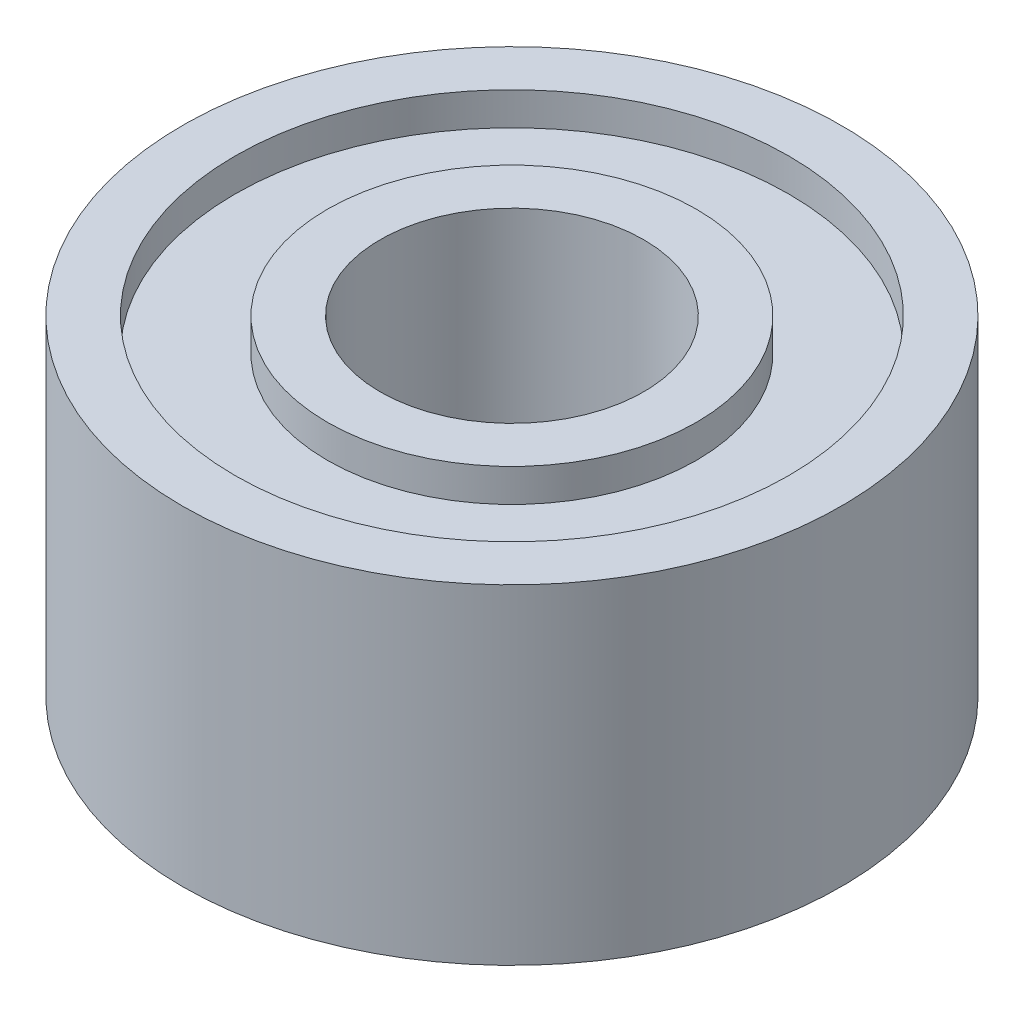
from build123d import *

# Parameters (mm, degrees)
SKETCH1_R           = 2.5
SKETCH1_R_2         = 1
BOSS_EXTRUDE1_DEPTH = 1.25
SKETCH2_R           = 2.1
SKETCH2_R_2         = 1.4
CUT_EXTRUDE1_DEPTH  = 0.25


with BuildPart() as part:
    # Sketch1 → Boss-Extrude1 (new body, symmetric)
    with BuildSketch(Plane(origin=(0, 0, 0), x_dir=(1, 0, 0), z_dir=(0, 1, 0))):
        Circle(SKETCH1_R)
        Circle(SKETCH1_R_2, mode=Mode.SUBTRACT)
    extrude(amount=BOSS_EXTRUDE1_DEPTH, both=True)

    # Sketch2 → Cut-Extrude1 (cut)
    with BuildSketch(Plane(origin=(0, 1.25, 0), x_dir=(1, 0, 0), z_dir=(0, 1, 0))):
        Circle(SKETCH2_R)
        Circle(SKETCH2_R_2, mode=Mode.SUBTRACT)
    cut_extrude1 = extrude(amount=-CUT_EXTRUDE1_DEPTH, mode=Mode.SUBTRACT)

    # Mirror1: Cut-Extrude1 across plane
    add(cut_extrude1.mirror(Plane.ZX), mode=Mode.SUBTRACT)


solid = part.part
